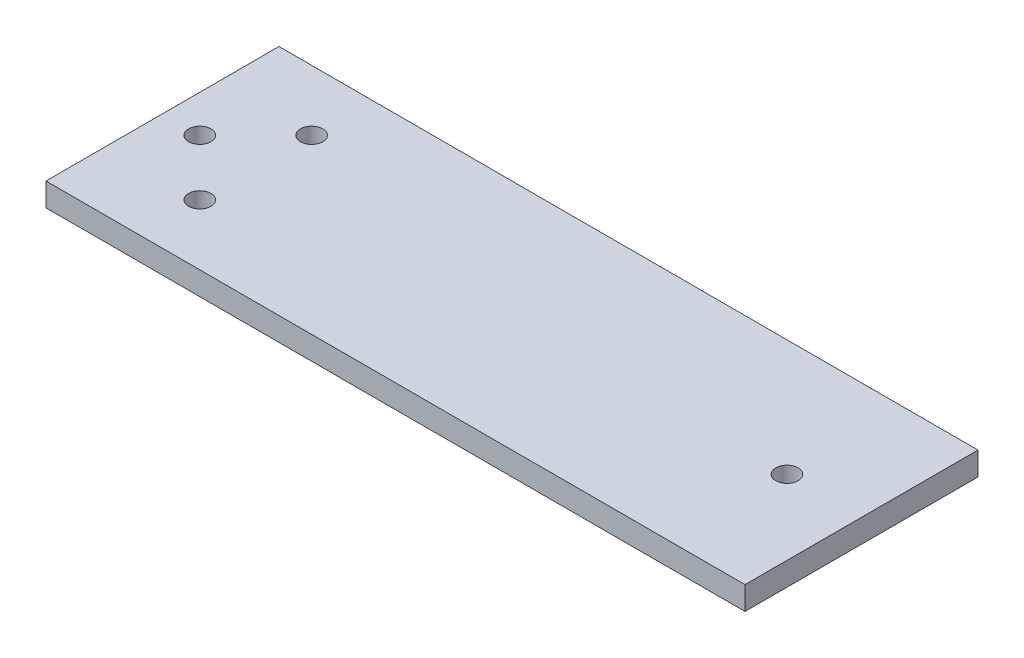
from build123d import *

# Parameters (mm, degrees)
SKETCH1_W           = 75
SKETCH1_H           = 25
BOSS_EXTRUDE1_DEPTH = 2.5
SKETCH2_R           = 1.2
CUT_EXTRUDE1_DEPTH  = 3.5


with BuildPart() as part:
    # Sketch1 → Boss-Extrude1 (new body)
    with BuildSketch(Plane(origin=(0, 0, 0), x_dir=(1, 0, 0), z_dir=(0, 1, 0))):
        Rectangle(SKETCH1_W, SKETCH1_H)
    extrude(amount=BOSS_EXTRUDE1_DEPTH)

    # Sketch2 → Cut-Extrude1 (cut, through all)
    with BuildSketch(Plane(origin=(0, 2.5, 0), x_dir=(1, 0, 0), z_dir=(0, 1, 0))):
        with Locations((-33.5, 0)):
            Circle(SKETCH2_R)
        with Locations((-27.5, 6)):
            Circle(SKETCH2_R)
        with Locations((-27.5, -6)):
            Circle(SKETCH2_R)
        with Locations((29.5, 0)):
            Circle(SKETCH2_R)
    extrude(amount=-CUT_EXTRUDE1_DEPTH, mode=Mode.SUBTRACT)


solid = part.part
